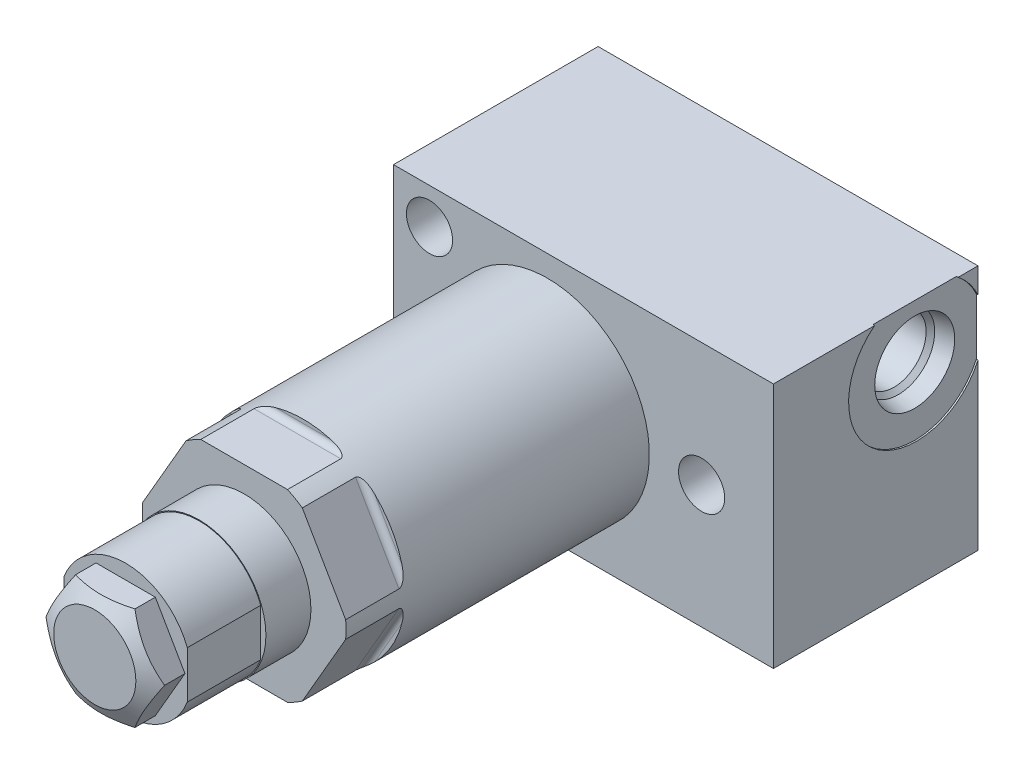
from build123d import *

# Parameters (mm, degrees)
SKETCH1_R           = 15.748
EXTRUDE1_DEPTH      = 67.8434
CUT_EXTRUDE1_DEPTH  = 18.8976
SKETCH11_W          = 18.3134
SKETCH11_H          = 10.3251
CUT_EXTRUDE10_DEPTH = 11.3538
EXTRUDE2_DEPTH      = 4.7752
SKETCH17_W          = 58.7248
SKETCH17_H          = 31.623
EXTRUDE4_DEPTH      = 19.05
SKETCH19_R          = 10.4775
CUT_EXTRUDE12_DEPTH = 0.254
SKETCH22_R          = 1.3335
CIRPATTERN2_COUNT   = 6
SKETCH23_W          = 3.5687
SKETCH23_H          = 31.623
HOLE1_AT_2_COUNT    = 2
HOLE1_AT_2_PITCH    = 44.196072988
HOLE1_AT_3_COUNT    = 2
HOLE1_AT_3_PITCH    = 26.974811959
SKETCH25_W          = 11.3538
SKETCH25_H          = 0.127


with BuildPart() as part:
    # Sketch1 → Extrude1 (new body)
    with BuildSketch(Plane.XY):
        Circle(SKETCH1_R)
    extrude(amount=EXTRUDE1_DEPTH)

    # Sketch2 → Cut-Extrude1 (cut, symmetric)
    with BuildSketch(Plane(origin=(0, 0, 0), x_dir=(0, 0, 1), z_dir=(1, 0, 0))):
        with BuildLine():
            Line((58.6994, 15.748), (58.6994, 15.1638))
            ThreePointArc((58.6994, 15.1638), (58.967221559, 14.517221559), (59.6138, 14.2494))
            Line((59.6138, 14.2494), (67.8434, 14.2494))
            Line((67.8434, 14.2494), (67.8434, 15.748))
            Line((67.8434, 15.748), (58.6994, 15.748))
        make_face()
    cut_extrude1 = extrude(amount=CUT_EXTRUDE1_DEPTH, both=True, mode=Mode.SUBTRACT)

    # Sketch10 → Cut-Revolve1 (revolve, cut)
    with BuildSketch(Plane(origin=(0, 0, 0), x_dir=(0, 0, 1), z_dir=(1, 0, 0)), mode=Mode.PRIVATE) as cut_revolve1_sk:
        Polygon((0, 14.8717), (7.7978, 14.8717), (8.6741, 15.748), (0, 15.748), align=None)
    revolve(cut_revolve1_sk.sketch.rotate(Axis((0, 0, -0.433705), (0, 0, 1)), 90), axis=Axis((0, 0, -0.433705), (0, 0, 1)), mode=Mode.SUBTRACT)  # turned: the seam where the file's is

    # Sketch11 → Revolve1 (revolve)
    with BuildSketch(Plane(origin=(0, 0, 0), x_dir=(0, 0, -1), z_dir=(1, 0, 0)), mode=Mode.PRIVATE) as revolve1_sk:
        with Locations((-77.0001, 5.16255)):
            Rectangle(SKETCH11_W, SKETCH11_H)
    revolve(revolve1_sk.sketch.rotate(Axis((0, 0, 71.154272279), (0, 0, -1)), 90), axis=Axis((0, 0, 71.154272279), (0, 0, -1)))  # turned: the seam where the file's is

    # Sketch14 → Cut-Extrude10 (cut)
    with BuildSketch(Plane.YX.offset(-86.1568)):
        with BuildLine():
            Line((-3.98523086, 9.525), (3.98523086, 9.525))
            ThreePointArc((3.98523086, 9.525), (0, 10.3251), (-3.98523086, 9.525))
        make_face()
        with BuildLine():
            Line((-3.98523086, -9.525), (3.98523086, -9.525))
            ThreePointArc((3.98523086, -9.525), (0, -10.3251), (-3.98523086, -9.525))
        make_face()
    extrude(amount=CUT_EXTRUDE10_DEPTH, mode=Mode.SUBTRACT)

    # Sketch15 → Extrude2 (add)
    with BuildSketch(Plane.XY.offset(86.1568)):
        Polygon((-4.582717762, 7.9375), (4.582717762, 7.9375), (9.165435523, 0), (4.582717762, -7.9375), (-4.582717762, -7.9375), (-9.165435523, 0), align=None)
    extrude(amount=EXTRUDE2_DEPTH)

    # Sketch16 → Cut-Revolve3 (revolve, cut)
    with BuildSketch(Plane(origin=(0, 0, 0), x_dir=(1, 0, 0), z_dir=(0, 1, 0))):
        Polygon((6.35, -90.932), (9.165435523, -89.306507543), (9.165435523, -90.932), align=None)
    revolve(axis=Axis((0, 0, 75.265274623), (0, 0, -1)), mode=Mode.SUBTRACT)

    # Sketch17 → Extrude4 (add, symmetric)
    with BuildSketch(Plane(origin=(0, 0, 0), x_dir=(-1, 0, 0), z_dir=(0, 1, 0))):
        with Locations((-5.5626, 5.1435)):
            Rectangle(SKETCH17_W, SKETCH17_H)
    extrude(amount=EXTRUDE4_DEPTH, both=True)

    # Sketch19 → Cut-Extrude12 (cut)
    with BuildSketch(Plane(origin=(34.925, -19.05, 0), x_dir=(0, 1, 0), z_dir=(1, 0, 0))):
        with Locations((29.845, -1.143)):
            Circle(SKETCH19_R)
    extrude(amount=-CUT_EXTRUDE12_DEPTH, mode=Mode.SUBTRACT)

    # S2D0001 → Cut-Revolve4 (revolve, cut)
    with BuildSketch(Plane(origin=(34.671, 10.795, -1.143), x_dir=(0, -1, 0), z_dir=(0, 0, 1)), mode=Mode.PRIVATE) as cut_revolve4_sk:
        Polygon((0, 0), (6.1849, 0), (5.642306865, -2.5527), (4.9784, -3.216606865), (4.9784, -17.272), (0, -17.272), align=None)
    revolve(cut_revolve4_sk.sketch.rotate(Axis((16.5354, 10.795, -1.143), (1, 0, 0)), 270), axis=Axis((16.5354, 10.795, -1.143), (1, 0, 0)), mode=Mode.SUBTRACT)  # turned: the seam where the file's is

    # Sketch21 → Cut-Revolve5 (revolve, cut)
    with BuildSketch(Plane(origin=(0, 0, -9.329310202), x_dir=(-1, 0, 0), z_dir=(0, 1, 0)), mode=Mode.PRIVATE) as cut_revolve5_sk:
        Polygon((0, -1.338689798), (7.9375, -1.338689798), (7.9375, 1.328310202), (3.4544, 1.328310202), (3.4544, 13.393310202), (0, 15.468923125), align=None)
    revolve(cut_revolve5_sk.sketch.rotate(Axis((0, 0, -11.508380646), (0, 0, 1)), 180), axis=Axis((0, 0, -11.508380646), (0, 0, 1)), mode=Mode.SUBTRACT)  # turned: the seam where the file's is

    # CirPattern2: Cut-Extrude1 ×6 about axis
    cirpattern2_axis = Axis((0, 0, 0), (0, 0, 1))
    for i in range(1, CIRPATTERN2_COUNT):
        add(cut_extrude1.rotate(cirpattern2_axis, i * 360 / CIRPATTERN2_COUNT), mode=Mode.SUBTRACT)

    # Sketch23 → Hole1 (revolve, cut)
    with BuildSketch(Plane(origin=(-18.2626, -13.4874, 20.955), x_dir=(0, -1, 0), z_dir=(1, 0, 0))):
        with Locations((1.78435, 15.8115)):
            Rectangle(SKETCH23_W, SKETCH23_H)
    hole1 = revolve(axis=Axis((-18.2626, -13.4874, -89.045), (0, 0, 1)), mode=Mode.SUBTRACT)

    # Hole1 at 2: Hole1 ×2
    with Locations(*[Vector(0.952297278, 0.30517191, 0) * (i * HOLE1_AT_2_PITCH) for i in range(1, HOLE1_AT_2_COUNT)]):
        add(hole1, mode=Mode.SUBTRACT)

    # Hole1 at 3: Hole1 ×2
    with Locations(*[Vector(0.000941619, 0.999999557, 0) * (i * HOLE1_AT_3_PITCH) for i in range(1, HOLE1_AT_3_COUNT)]):
        add(hole1, mode=Mode.SUBTRACT)

    # Sketch25 → Cut-Revolve6 (revolve, cut)
    with BuildSketch(Plane(origin=(0, 0, 0), x_dir=(0, 0, -1), z_dir=(1, 0, 0)), mode=Mode.PRIVATE) as cut_revolve6_sk:
        with Locations((-80.4799, 10.2616)):
            Rectangle(SKETCH25_W, SKETCH25_H)
    revolve(cut_revolve6_sk.sketch.rotate(Axis((0, 0, -10.707857417), (0, 0, 1)), 270), axis=Axis((0, 0, -10.707857417), (0, 0, 1)), mode=Mode.SUBTRACT)  # turned: the seam where the file's is


with BuildPart() as body_2:
    # Sketch22 → Revolve2 (revolve)
    with BuildSketch(Plane(origin=(0, 0, -9.329310202), x_dir=(-1, 0, 0), z_dir=(0, 1, 0))):
        with Locations((-6.604, -0.005189798)):
            Circle(SKETCH22_R)
    revolve(axis=Axis((0, 0, -10.80135), (0, 0, 1)))


solid = Compound([part.part, body_2.part])
